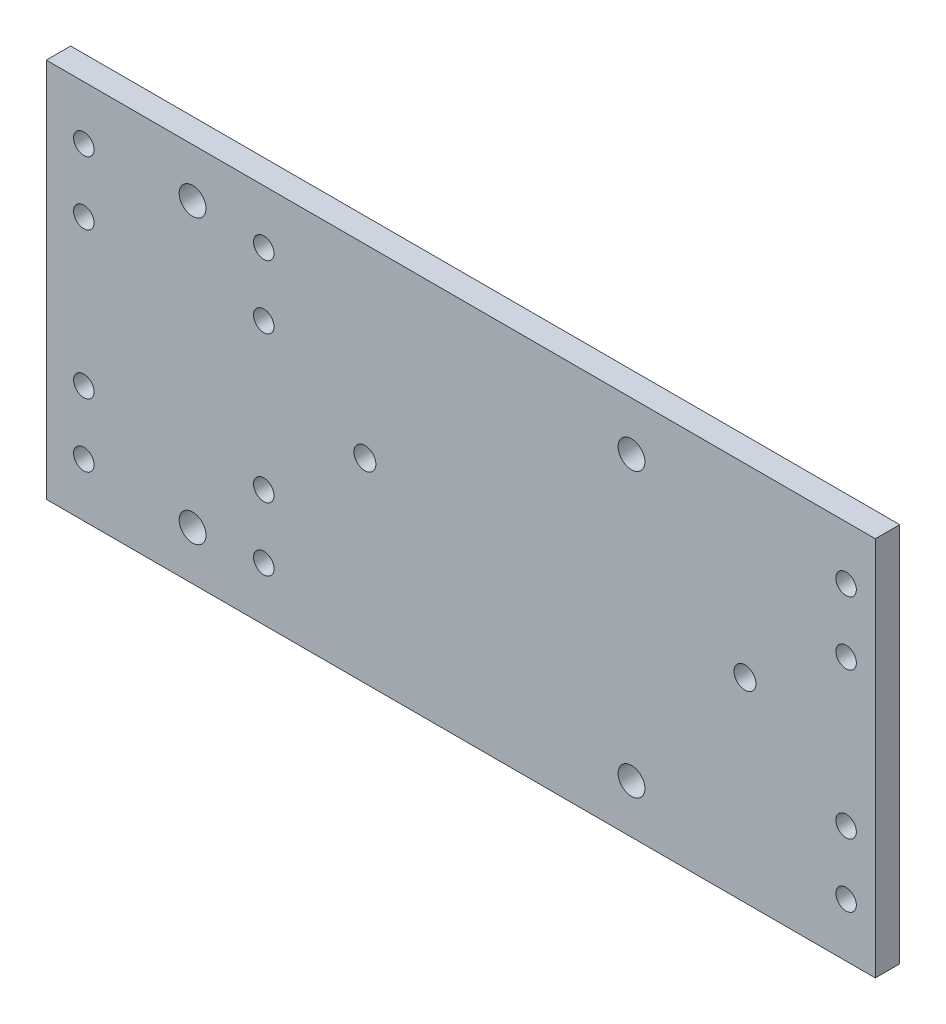
from build123d import *

# Parameters (mm, degrees)
SKETCH_3_W                  = 170
SKETCH_3_H                  = 78
SKETCH_3_R                  = 2.75
SKETCH_3_R_2                = 2.25
EXTRUDE_1_DEPTH             = 5
HOLE_WIZARD_M5_1_AT_2_COUNT = 2
HOLE_WIZARD_M5_1_AT_2_PITCH = 13
HOLE_WIZARD_M5_1_AT_3_COUNT = 2
HOLE_WIZARD_M5_1_AT_3_PITCH = 30
HOLE_WIZARD_M5_1_AT_4_COUNT = 2
HOLE_WIZARD_M5_1_AT_4_PITCH = 43
PATTERN_LINEAR_1_COUNT      = 2
PATTERN_LINEAR_1_PITCH      = 36.9
PATTERN_LINEAR_2_COUNT      = 2
PATTERN_LINEAR_2_PITCH      = 156.3


with BuildPart() as part:
    # 草图3 → 凸台-拉伸1 (new body)
    with BuildSketch(Plane.XY):
        with Locations((-85, 39)):
            Rectangle(SKETCH_3_W, SKETCH_3_H)
        with Locations((-140, 68)):
            Circle(SKETCH_3_R, mode=Mode.SUBTRACT)
        with Locations((-140, 10)):
            Circle(SKETCH_3_R, mode=Mode.SUBTRACT)
        with Locations((-50, 10)):
            Circle(SKETCH_3_R, mode=Mode.SUBTRACT)
        with Locations((-50, 68)):
            Circle(SKETCH_3_R, mode=Mode.SUBTRACT)
        with Locations((-104.6634, 40)):
            Circle(SKETCH_3_R_2, mode=Mode.SUBTRACT)
        with Locations((-26.7334, 40)):
            Circle(SKETCH_3_R_2, mode=Mode.SUBTRACT)
    extrude(amount=EXTRUDE_1_DEPTH)

    # 草图6 → M5 螺纹孔1 (revolve, cut)
    with BuildSketch(Plane(origin=(-162.3, 54, 5), x_dir=(0, -1, 0), z_dir=(1, 0, 0))):
        Polygon((0, 0), (0, 13.6618073), (2.1, 12.4), (2.1, 0), align=None)
    hole_wizard_m5_1 = revolve(axis=Axis((-162.3, 54, 11.35), (0, 0, -1)), mode=Mode.SUBTRACT)

    # M5 螺纹孔1 at 2: M5 螺纹孔1 ×2
    with Locations(*[(0, i * HOLE_WIZARD_M5_1_AT_2_PITCH, 0) for i in range(1, HOLE_WIZARD_M5_1_AT_2_COUNT)]):
        add(hole_wizard_m5_1, mode=Mode.SUBTRACT)

    # M5 螺纹孔1 at 3: M5 螺纹孔1 ×2
    with Locations(*[(0, -i * HOLE_WIZARD_M5_1_AT_3_PITCH, 0) for i in range(1, HOLE_WIZARD_M5_1_AT_3_COUNT)]):
        add(hole_wizard_m5_1, mode=Mode.SUBTRACT)

    # M5 螺纹孔1 at 4: M5 螺纹孔1 ×2
    with Locations(*[(0, -i * HOLE_WIZARD_M5_1_AT_4_PITCH, 0) for i in range(1, HOLE_WIZARD_M5_1_AT_4_COUNT)]):
        add(hole_wizard_m5_1, mode=Mode.SUBTRACT)

    # 阵列(线性)1: M5 螺纹孔1 ×2
    with Locations(*[(i * PATTERN_LINEAR_1_PITCH, 0, 0) for i in range(1, PATTERN_LINEAR_1_COUNT)]):
        add(hole_wizard_m5_1, mode=Mode.SUBTRACT)

    # 阵列(线性)1 copy 1 sketch → 阵列(线性)1 copy 1 (revolve, cut)
    with BuildSketch(Plane(origin=(-125.4, 67, 5), x_dir=(0, -1, 0), z_dir=(1, 0, 0))):
        Polygon((0, 0), (0, 13.6618073), (2.1, 12.4), (2.1, 0), align=None)
    revolve(axis=Axis((-125.4, 67, 11.35), (0, 0, -1)), mode=Mode.SUBTRACT)

    # 阵列(线性)1 copy 2 sketch → 阵列(线性)1 copy 2 (revolve, cut)
    with BuildSketch(Plane(origin=(-125.4, 24, 5), x_dir=(0, -1, 0), z_dir=(1, 0, 0))):
        Polygon((0, 0), (0, 13.6618073), (2.1, 12.4), (2.1, 0), align=None)
    revolve(axis=Axis((-125.4, 24, 11.35), (0, 0, -1)), mode=Mode.SUBTRACT)

    # 阵列(线性)1 copy 3 sketch → 阵列(线性)1 copy 3 (revolve, cut)
    with BuildSketch(Plane(origin=(-125.4, 11, 5), x_dir=(0, -1, 0), z_dir=(1, 0, 0))):
        Polygon((0, 0), (0, 13.6618073), (2.1, 12.4), (2.1, 0), align=None)
    revolve(axis=Axis((-125.4, 11, 11.35), (0, 0, -1)), mode=Mode.SUBTRACT)

    # 阵列(线性)2: M5 螺纹孔1 ×2
    with Locations(*[(i * PATTERN_LINEAR_2_PITCH, 0, 0) for i in range(1, PATTERN_LINEAR_2_COUNT)]):
        add(hole_wizard_m5_1, mode=Mode.SUBTRACT)

    # 阵列(线性)2 copy 1 sketch → 阵列(线性)2 copy 1 (revolve, cut)
    with BuildSketch(Plane(origin=(-6, 67, 5), x_dir=(0, -1, 0), z_dir=(1, 0, 0))):
        Polygon((0, 0), (0, 13.6618073), (2.1, 12.4), (2.1, 0), align=None)
    revolve(axis=Axis((-6, 67, 11.35), (0, 0, -1)), mode=Mode.SUBTRACT)

    # 阵列(线性)2 copy 2 sketch → 阵列(线性)2 copy 2 (revolve, cut)
    with BuildSketch(Plane(origin=(-6, 24, 5), x_dir=(0, -1, 0), z_dir=(1, 0, 0))):
        Polygon((0, 0), (0, 13.6618073), (2.1, 12.4), (2.1, 0), align=None)
    revolve(axis=Axis((-6, 24, 11.35), (0, 0, -1)), mode=Mode.SUBTRACT)

    # 阵列(线性)2 copy 3 sketch → 阵列(线性)2 copy 3 (revolve, cut)
    with BuildSketch(Plane(origin=(-6, 11, 5), x_dir=(0, -1, 0), z_dir=(1, 0, 0))):
        Polygon((0, 0), (0, 13.6618073), (2.1, 12.4), (2.1, 0), align=None)
    revolve(axis=Axis((-6, 11, 11.35), (0, 0, -1)), mode=Mode.SUBTRACT)


solid = part.part
